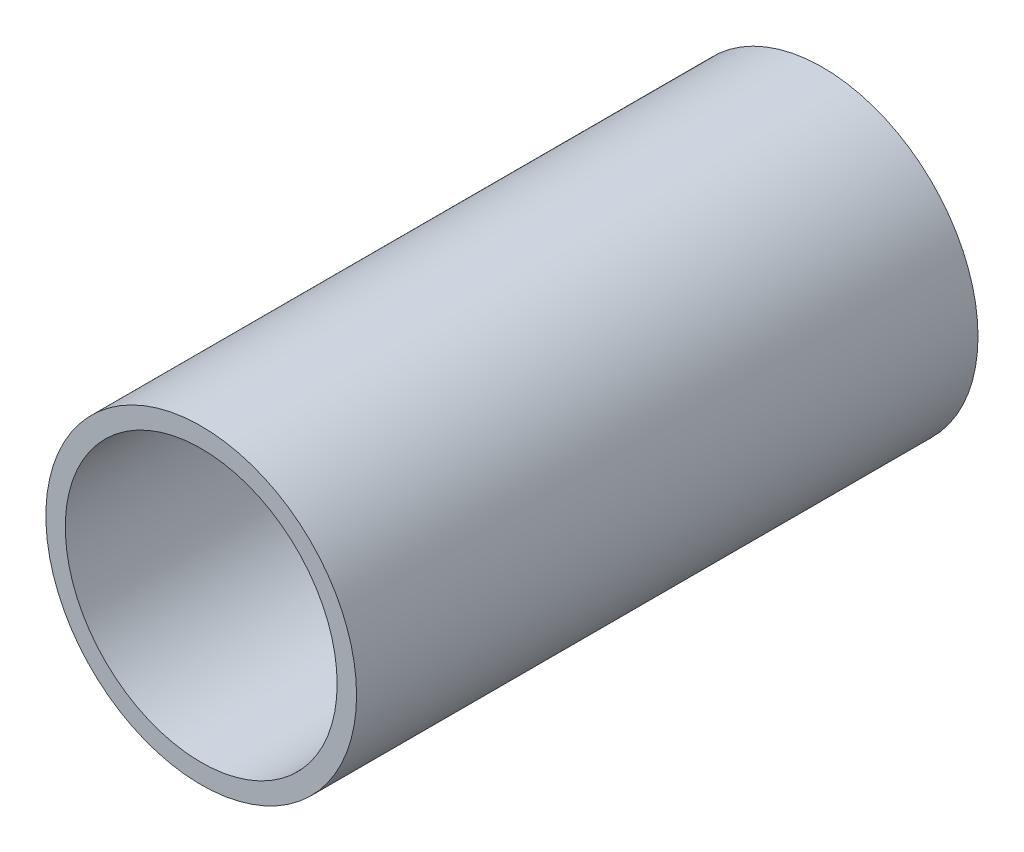
from build123d import *

# Parameters (mm, degrees)
SKETCH1_R           = 6.35
SKETCH1_R_2         = 5.55625
BOSS_EXTRUDE1_DEPTH = 25.4


with BuildPart() as part:
    # Sketch1 → Boss-Extrude1 (new body)
    with BuildSketch(Plane.XY):
        Circle(SKETCH1_R)
        Circle(SKETCH1_R_2, mode=Mode.SUBTRACT)
    extrude(amount=BOSS_EXTRUDE1_DEPTH)


solid = part.part
